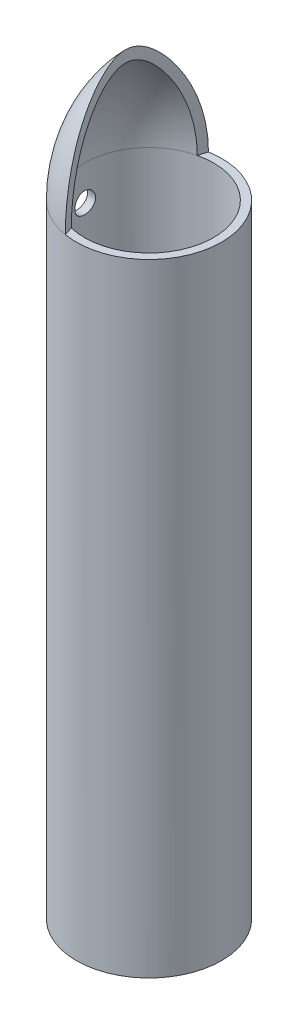
from build123d import *

# Parameters (mm, degrees)
SKETCH1_R           = 10.5
SKETCH1_R_2         = 9.35
BOSS_EXTRUDE1_DEPTH = 45
SKETCH3_R           = 33.16
CUT_EXTRUDE1_DEPTH  = 21.0000001
SKETCH4_R           = 1.5
CUT_EXTRUDE2_DEPTH  = 11.5000001


with BuildPart() as part:
    # Sketch1 → Boss-Extrude1 (new body, symmetric)
    with BuildSketch(Plane(origin=(0, 0, 0), x_dir=(1, 0, 0), z_dir=(0, 1, 0))):
        Circle(SKETCH1_R)
        Circle(SKETCH1_R_2, mode=Mode.SUBTRACT)
    extrude(amount=BOSS_EXTRUDE1_DEPTH, both=True)

    # Sketch2 → Revolve1 (revolve)
    with BuildSketch(Plane.XY):
        with BuildLine():
            Line((10.5, 45), (9.35, 45))
            ThreePointArc((9.35, 45), (6.880803245, 55.402649617), (0, 63.585961804))
            Line((0, 63.585961804), (0, 65))
            ThreePointArc((0, 65), (7.715441901, 56.294356998), (10.5, 45))
        make_face()
    revolve(axis=Axis((0, 65, 0), (0, -1, 0)))

    # Sketch3 → Cut-Extrude1 (cut, through all)
    with BuildSketch(Plane(origin=(0, 45, 0), x_dir=(1, 0, 0), z_dir=(0, 1, 0))):
        with Locations((29.75, 0)):
            Circle(SKETCH3_R)
    extrude(amount=CUT_EXTRUDE1_DEPTH, mode=Mode.SUBTRACT)

    # Sketch4 → Cut-Extrude2 (cut, through all)
    with BuildSketch(Plane(origin=(0, 0, 0), x_dir=(0, 0, -1), z_dir=(1, 0, 0))):
        with Locations((0, 40)):
            Circle(SKETCH4_R)
    extrude(amount=-CUT_EXTRUDE2_DEPTH, mode=Mode.SUBTRACT)


solid = part.part
